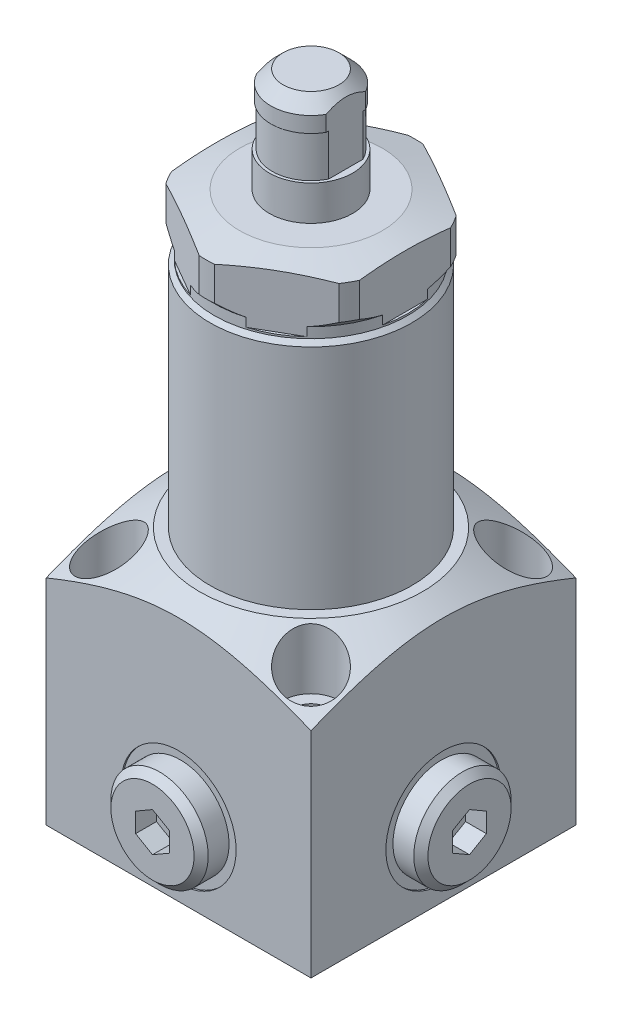
from build123d import *

# Parameters (mm, degrees)
SKETCH1_W           = 15
SKETCH1_H           = 59.5
HEX_HEAD_DEPTH      = 8.5
SKETCH6_W           = 14
SKETCH6_H           = 2.5
SKETCH15_W          = 1.016212988
SKETCH15_H          = 3.99
SKETCH15_W_2        = 0.956857294
CUT_EXTRUDE1_DEPTH  = 18.5
SKETCH16_R          = 5.98
EXTRUDE3_DEPTH      = 11.01
SKETCH17_W          = 0.41
SKETCH17_H          = 5.99
SKETCH18_W          = 0.57
SKETCH18_H          = 5.99
CUT_EXTRUDE2_DEPTH  = 18.5
SKETCH19_W          = 38
SKETCH19_H          = 38
CM_BASE_DEPTH       = 37
CUT_EXTRUDE3_START  = -9
SKETCH21_R          = 4
CUT_EXTRUDE3_DEPTH  = 9
SKETCH22_R          = 2.25
CUT_EXTRUDE4_DEPTH  = 28
SKETCH38_R          = 0.95
SKETCH39_R          = 0.95
CUT_EXTRUDE11_DEPTH = 3
CUT_EXTRUDE10_DEPTH = 3
EXTRUDE5_DEPTH      = 2.54


with BuildPart() as part:
    # Sketch1 → Stock (revolve)
    with BuildSketch(Plane.XY, mode=Mode.PRIVATE) as stock_sk:
        with Locations((7.5, 13.160229068)):
            Rectangle(SKETCH1_W, SKETCH1_H)
    revolve(stock_sk.sketch.rotate(Axis((0, -13.824084619, 0), (0, 1, 0)), 90), axis=Axis((0, -13.824084619, 0), (0, 1, 0)))  # turned: the seam where the file's is

    # Sketch3 → HEX_HEAD (cut)
    with BuildSketch(Plane(origin=(0, 42.910229068, 0), x_dir=(1, 0, 0), z_dir=(0, 1, 0))):
        with BuildLine():
            ThreePointArc((12.412375826, 8.422168743), (7.5, 12.990381057), (1.087624174, 14.960517159))
            Line((1.087624174, 14.960517159), (12.412375826, 8.422168743))
        make_face()
        with BuildLine():
            Line((-12.412375826, 8.422168743), (-1.087624174, 14.960517159))
            ThreePointArc((-1.087624174, 14.960517159), (-7.5, 12.990381057), (-12.412375826, 8.422168743))
        make_face()
        with BuildLine():
            Line((13.5, 6.538348415), (13.5, -6.538348415))
            ThreePointArc((13.5, -6.538348415), (15, 0), (13.5, 6.538348415))
        make_face()
        with BuildLine():
            Line((-13.5, -6.538348415), (-13.5, 6.538348415))
            ThreePointArc((-13.5, 6.538348415), (-15, 0), (-13.5, -6.538348415))
        make_face()
        with BuildLine():
            Line((12.412375826, -8.422168743), (1.087624174, -14.960517159))
            ThreePointArc((1.087624174, -14.960517159), (7.5, -12.990381057), (12.412375826, -8.422168743))
        make_face()
        with BuildLine():
            Line((-1.087624174, -14.960517159), (-12.412375826, -8.422168743))
            ThreePointArc((-12.412375826, -8.422168743), (-7.5, -12.990381057), (-1.087624174, -14.960517159))
        make_face()
    extrude(amount=-HEX_HEAD_DEPTH, mode=Mode.SUBTRACT)

    # Sketch4 → CROWN (revolve, cut)
    with BuildSketch(Plane.XY, mode=Mode.PRIVATE) as crown_sk:
        Polygon((10.25, 42.910229068), (20.75899698, 42.910229068), (20.75899698, 40.094351814), align=None)
    revolve(crown_sk.sketch.rotate(Axis((0, -13.039086361, 0), (0, 1, 0)), 90), axis=Axis((0, -13.039086361, 0), (0, 1, 0)), mode=Mode.SUBTRACT)  # turned: the seam where the file's is

    # Sketch5 → OD_PROFILE (revolve, cut)
    with BuildSketch(Plane.XY, mode=Mode.PRIVATE) as od_profile_sk:
        Polygon((15, 36.785229068), (13.875, 35.660229068), (13.875, 34.160229068), (14.475, 33.560229068), (14.475, -9.329770932), (14.125, -9.679770932), (14.125, -16.589770932), (15, -16.589770932), align=None)
    revolve(od_profile_sk.sketch.rotate(Axis((0, -14.613972704, 0), (0, 1, 0)), 90), axis=Axis((0, -14.613972704, 0), (0, 1, 0)), mode=Mode.SUBTRACT)  # turned: the seam where the file's is

    # Sketch6 → RETAINER (revolve)
    with BuildSketch(Plane.XY, mode=Mode.PRIVATE) as retainer_sk:
        with Locations((7, -17.839770932)):
            Rectangle(SKETCH6_W, SKETCH6_H)
    revolve(retainer_sk.sketch.rotate(Axis((0, -16.121539511, 0), (0, 1, 0)), 90), axis=Axis((0, -16.121539511, 0), (0, 1, 0)))  # turned: the seam where the file's is



with BuildPart() as body_2:
    # Sketch14 → Revolve1 (revolve)
    with BuildSketch(Plane.XY, mode=Mode.PRIVATE) as revolve1_sk:
        Polygon((0, 57.910229068), (4, 57.910229068), (5.75, 56.160229068), (5.75, 53.920229068), (0, 53.920229068), align=None)
    revolve(revolve1_sk.sketch.rotate(Axis((0, -16.622581477, 0), (0, 1, 0)), 90), axis=Axis((0, -16.622581477, 0), (0, 1, 0)))  # turned: the seam where the file's is

    # Sketch15 → Cut-Extrude1 (cut, symmetric)
    with BuildSketch(Plane.XY):
        with Locations((5.508106494, 55.915229068)):
            Rectangle(SKETCH15_W, SKETCH15_H)
        with Locations((-5.478428647, 55.915229068)):
            Rectangle(SKETCH15_W_2, SKETCH15_H)
    extrude(amount=CUT_EXTRUDE1_DEPTH, both=True, mode=Mode.SUBTRACT)


with BuildPart() as part_1:
    add(part.part)

    add(body_2.part)  # Extrude3 merges body 2
    # Sketch16 → Extrude3 (add)
    with BuildSketch(Plane(origin=(0, 42.910229068, 0), x_dir=(1, 0, 0), z_dir=(0, 1, 0))):
        with Locations(Location((0, 0, 0), (0, 0, 90))):  # turned: the seam where the file's is
            Circle(SKETCH16_R)
    extrude(amount=EXTRUDE3_DEPTH)

    # Sketch17 → Cut-Revolve1 (revolve, cut)
    with BuildSketch(Plane.XY, mode=Mode.PRIVATE) as cut_revolve1_sk:
        with Locations((5.775, 50.925229068)):
            Rectangle(SKETCH17_W, SKETCH17_H)
    revolve(cut_revolve1_sk.sketch.rotate(Axis((0, -16.899527135, 0), (0, 1, 0)), 90), axis=Axis((0, -16.899527135, 0), (0, 1, 0)), mode=Mode.SUBTRACT)  # turned: the seam where the file's is

    # Sketch18 → Cut-Extrude2 (cut, symmetric)
    with BuildSketch(Plane.XY):
        with Locations((-5.285, 50.925229068)):
            Rectangle(SKETCH18_W, SKETCH18_H)
        with Locations((5.285, 50.925229068)):
            Rectangle(SKETCH18_W, SKETCH18_H)
    extrude(amount=CUT_EXTRUDE2_DEPTH, both=True, mode=Mode.SUBTRACT)

    # Sketch19 → CM_BASE (add)
    with BuildSketch(Plane.XZ.offset(36.089770932)):
        Rectangle(SKETCH19_W, SKETCH19_H)
    extrude(amount=-CM_BASE_DEPTH)

    # Sketch21 → Cut-Extrude3 (cut)
    with BuildSketch(Plane(origin=(0, 0.910229068, 0), x_dir=(1, 0, 0), z_dir=(0, 1, 0)).offset(CUT_EXTRUDE3_START)):
        with Locations(Location((-14.5, 14.5, 0), (0, 0, 270))):  # turned: the seam where the file's is
            Circle(SKETCH21_R)
        with Locations(Location((14.5, 14.5, 0), (0, 0, 90))):  # turned: the seam where the file's is
            Circle(SKETCH21_R)
        with Locations(Location((-14.5, -14.5, 0), (0, 0, 90))):  # turned: the seam where the file's is
            Circle(SKETCH21_R)
        with Locations(Location((14.5, -14.5, 0), (0, 0, 270))):  # turned: the seam where the file's is
            Circle(SKETCH21_R)
    extrude(amount=CUT_EXTRUDE3_DEPTH, mode=Mode.SUBTRACT)

    # Sketch22 → Cut-Extrude4 (cut)
    with BuildSketch(Plane(origin=(0, -8.089770932, 0), x_dir=(1, 0, 0), z_dir=(0, 1, 0))):
        with Locations(Location((-14.5, 14.5, 0), (0, 0, 270))):  # turned: the seam where the file's is
            Circle(SKETCH22_R)
        with Locations(Location((14.5, 14.5, 0), (0, 0, 270))):  # turned: the seam where the file's is
            Circle(SKETCH22_R)
        with Locations(Location((14.5, -14.5, 0), (0, 0, 270))):  # turned: the seam where the file's is
            Circle(SKETCH22_R)
        with Locations(Location((-14.5, -14.5, 0), (0, 0, 270))):  # turned: the seam where the file's is
            Circle(SKETCH22_R)
    extrude(amount=-CUT_EXTRUDE4_DEPTH, mode=Mode.SUBTRACT)

    # Sketch23 → BASE_CROWN (revolve, cut)
    with BuildSketch(Plane(origin=(0, 0, 0), x_dir=(0.707106781, 0, 0.707106781), z_dir=(-0.707106781, 0, 0.707106781)), mode=Mode.PRIVATE) as base_crown_sk:
        Polygon((16, 0.910229068), (28.016829366, 0.910229068), (28.016829366, -6.027690601), align=None)
    revolve(base_crown_sk.sketch.rotate(Axis((0, -33.608380835, 0), (0, 1, 0)), 135), axis=Axis((0, -33.608380835, 0), (0, 1, 0)), mode=Mode.SUBTRACT)  # turned: the seam where the file's is

    # Sketch26 → Cut-Revolve3 (revolve, cut)
    with BuildSketch(Plane.XZ.offset(25.589770932), mode=Mode.PRIVATE) as cut_revolve3_sk:
        Polygon((0, 5.524496494), (-4.4195, 8.18), (-4.4195, 18.2125), (-4.953, 18.746), (-8.255, 18.746), (-8.255, 19), (0, 19), align=None)
    revolve(cut_revolve3_sk.sketch.rotate(Axis((0, -25.589770932, 21.009478673), (0, 0, -1)), 180), axis=Axis((0, -25.589770932, 21.009478673), (0, 0, -1)), mode=Mode.SUBTRACT)  # turned: the seam where the file's is

    # Sketch30 → Cut-Revolve4 (revolve, cut)
    with BuildSketch(Plane.XY, mode=Mode.PRIVATE) as cut_revolve4_sk:
        Polygon((4.990996494, -25.589770932), (7.6465, -30.009270932), (18.2125, -30.009270932), (18.746, -30.542770932), (18.746, -33.844770932), (19, -33.844770932), (19, -25.589770932), align=None)
    revolve(cut_revolve4_sk.sketch.rotate(Axis((18.400976111, -25.589770932, 0), (-1, 0, 0)), 180), axis=Axis((18.400976111, -25.589770932, 0), (-1, 0, 0)), mode=Mode.SUBTRACT)  # turned: the seam where the file's is

    # Sketch32 → HOLE_1 (revolve, cut)
    with BuildSketch(Plane.XZ.offset(25.589770932)):
        Polygon((0, -5.012564435), (2.1, -6.225), (2.1, -18.225), (2.625, -18.75), (6, -18.75), (6, -19), (0, -19), align=None)
    revolve(axis=Axis((0, -25.589770932, 19.052132701), (0, 0, -1)), mode=Mode.SUBTRACT)

    # Sketch34 → Cut-Revolve6 (revolve, cut)
    with BuildSketch(Plane.XY.offset(-9), mode=Mode.PRIVATE) as cut_revolve6_sk:
        Polygon((0, -23.223745528), (-1.5, -24.089770932), (-1.5, -34.514770932), (-1.625, -34.639770932), (-5.195, -34.639770932), (-5.195, -36.089770932), (0, -36.089770932), align=None)
    revolve(cut_revolve6_sk.sketch.rotate(Axis((0, -32.860447778, -9), (0, 1, 0)), 270), axis=Axis((0, -32.860447778, -9), (0, 1, 0)), mode=Mode.SUBTRACT)  # turned: the seam where the file's is

    # Sketch36 → Cut-Revolve7 (revolve, cut)
    with BuildSketch(Plane.XY.offset(7)):
        Polygon((7, -23.223745528), (5.5, -24.089770932), (5.5, -34.514770932), (5.375, -34.639770932), (2, -34.639770932), (2, -36.089770932), (7, -36.089770932), align=None)
    revolve(axis=Axis((7, 12.484399153, 7), (0, -1, 0)), mode=Mode.SUBTRACT)

    # Sketch38 → Revolve2 (revolve)
    with BuildSketch(Plane(origin=(0, 0, 0), x_dir=(0, 0, -1), z_dir=(1, 0, 0))):
        with Locations((13.35, -35.499770932)):
            Circle(SKETCH38_R)
    revolve(axis=Axis((0, -33.480701769, -9), (0, 1, 0)))

    # Sketch39 → Revolve3 (revolve)
    with BuildSketch(Plane.XY.offset(7), mode=Mode.PRIVATE) as revolve3_sk:
        with Locations((11.35, -35.499770932)):
            Circle(SKETCH39_R)
    revolve(revolve3_sk.sketch.rotate(Axis((7, -33.659619971, 7), (0, 1, 0)), 180), axis=Axis((7, -33.659619971, 7), (0, 1, 0)))  # turned: the seam where the file's is

    # Sketch40 → Revolve4 (revolve)
    with BuildSketch(Plane.XY, mode=Mode.PRIVATE) as revolve4_sk:
        Polygon((18.746, -32.574770932), (21.731, -32.574770932), (22.746, -31.559770932), (22.746, -25.589770932), (18.746, -25.589770932), align=None)
    revolve(revolve4_sk.sketch.rotate(Axis((25.555955883, -25.589770932, 0), (-1, 0, 0)), 180), axis=Axis((25.555955883, -25.589770932, 0), (-1, 0, 0)))  # turned: the seam where the file's is

    # Sketch48 → Cut-Extrude11 (cut)
    with BuildSketch(Plane(origin=(22.746, 0, 0), x_dir=(0, 0, -1), z_dir=(1, 0, 0))):
        Polygon((0, -22.785580675), (2.4285, -24.187675803), (2.4285, -26.991866061), (0, -28.39396119), (-2.4285, -26.991866061), (-2.4285, -24.187675803), align=None)
    extrude(amount=-CUT_EXTRUDE11_DEPTH, mode=Mode.SUBTRACT)

    # Sketch42 → Revolve5 (revolve)
    with BuildSketch(Plane(origin=(0, 0, 0), x_dir=(0, 0, -1), z_dir=(1, 0, 0)), mode=Mode.PRIVATE) as revolve5_sk:
        Polygon((-18.746, -25.589770932), (-18.746, -18.604770932), (-21.731, -18.604770932), (-22.746, -19.619770932), (-22.746, -25.589770932), align=None)
    revolve(revolve5_sk.sketch.rotate(Axis((0, -25.589770932, -19.368076846), (0, 0, 1)), 270), axis=Axis((0, -25.589770932, -19.368076846), (0, 0, 1)))  # turned: the seam where the file's is

    # Sketch43 → Cut-Extrude10 (cut)
    with BuildSketch(Plane.XY.offset(22.746)):
        Polygon((0, -22.785580675), (2.4285, -24.187675803), (2.4285, -26.991866061), (0, -28.39396119), (-2.4285, -26.991866061), (-2.4285, -24.187675803), align=None)
    extrude(amount=-CUT_EXTRUDE10_DEPTH, mode=Mode.SUBTRACT)


with BuildPart() as body_2_2:
    # Sketch44 → Extrude5 (new body)
    with BuildSketch(Plane(origin=(0, 0, -19), x_dir=(-1, 0, 0), z_dir=(0, 0, -1))):
        Polygon((-2.020725942, -22.089770932), (2.020725942, -22.089770932), (4.041451884, -25.589770932), (2.020725942, -29.089770932), (-2.020725942, -29.089770932), (-4.041451884, -25.589770932), align=None)
    extrude(amount=EXTRUDE5_DEPTH)

    # Sketch47 → Revolve6 (revolve)
    with BuildSketch(Plane(origin=(0, 0, 0), x_dir=(0, 0, -1), z_dir=(1, 0, 0)), mode=Mode.PRIVATE) as revolve6_sk:
        Polygon((21.54, -22.089770932), (22.575, -23.124770932), (22.575, -25.589770932), (21.54, -25.589770932), align=None)
    revolve(revolve6_sk.sketch.rotate(Axis((0, -25.589770932, -23.811787553), (0, 0, 1)), 270), axis=Axis((0, -25.589770932, -23.811787553), (0, 0, 1)))  # turned: the seam where the file's is


solid = Compound([part_1.part, body_2_2.part])
